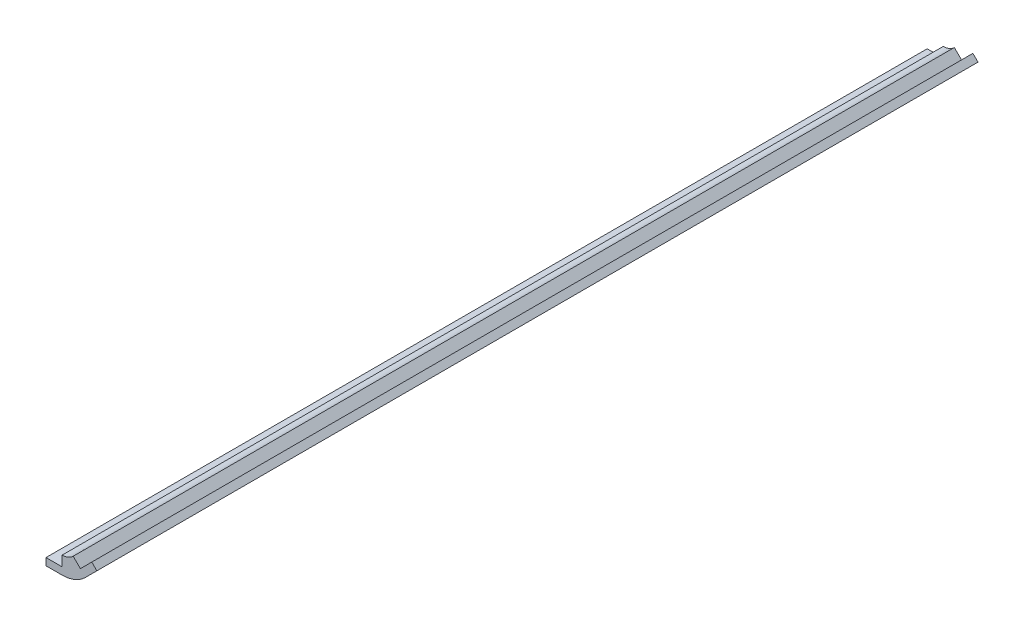
from build123d import *

# Parameters (mm, degrees)
SKETCH7_W           = 4.7625
SKETCH7_H           = 2.12122512
BOSS_EXTRUDE2_DEPTH = 130.175
BOSS_EXTRUDE3_DEPTH = 130.175
BOSS_EXTRUDE4_DEPTH = 130.175


with BuildPart() as part:
    # Sketch7 → Boss-Extrude2 (new, symmetric)
    with BuildSketch(Plane.XY):
        with Locations((-4.92125, -2.560612608)):
            Rectangle(SKETCH7_W, SKETCH7_H)
    extrude(amount=BOSS_EXTRUDE2_DEPTH, both=True)



with BuildPart() as body_2:
    # Sketch8 → Boss-Extrude3 (new, symmetric)
    with BuildSketch(Plane.XY):
        Polygon((2.85671143, 0.735391018), (6.224307475, 4.102987064), (7.724240142, 2.603054397), (4.356644097, -0.764541648), align=None)
    extrude(amount=BOSS_EXTRUDE3_DEPTH, both=True)


with BuildPart() as part_1:
    add(part.part)

    add(body_2.part)  # Boss-Extrude4 merges body 2
    # Sketch11 → Boss-Extrude4 (add, symmetric)
    with BuildSketch(Plane.XY):
        with BuildLine():
            Line((-2.54, -1.500000048), (-7.3025, -1.500000048))
            Line((-7.3025, -1.500000048), (-7.3025, -3.621225168))
            Line((-7.3025, -3.621225168), (-2.54, -3.621225168))
            ThreePointArc((-2.54, -3.621225168), (1.192436889, -2.87879731), (4.356644097, -0.764541648))
            Line((4.356644097, -0.764541648), (7.724240142, 2.603054397))
            Line((7.724240142, 2.603054397), (6.224307475, 4.102987064))
            Line((6.224307475, 4.102987064), (2.85671143, 0.735391018))
            Line((2.85671143, 0.735391018), (0.735391018, 2.85671143))
            ThreePointArc((0.735391018, 2.85671143), (-0.767371154, 1.852597848), (-2.54, 1.500000048))
            Line((-2.54, 1.500000048), (-2.54, -1.500000048))
        make_face()
    extrude(amount=BOSS_EXTRUDE4_DEPTH, both=True)


solid = part_1.part
